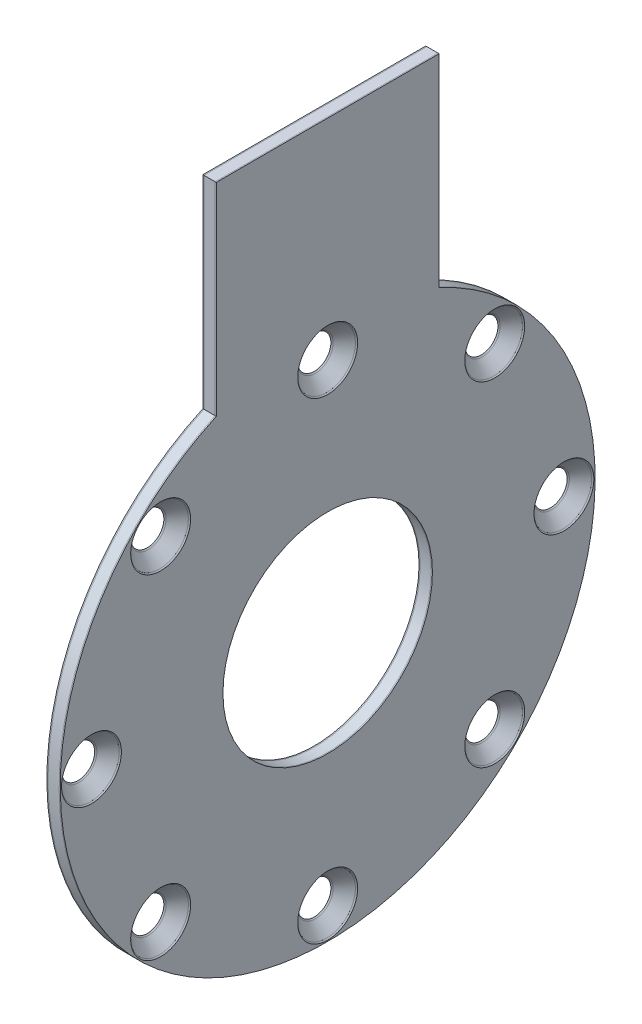
from build123d import *

# Parameters (mm, degrees)
SKETCH1_R                                    = 60
SKETCH1_R_2                                  = 23.5
BOSS_EXTRUDE1_DEPTH                          = 0.25
SKETCH4_R                                    = 23.5
BOSS_EXTRUDE4_DEPTH                          = 2.5
SKETCH5_R                                    = 23.5
BOSS_EXTRUDE5_DEPTH                          = 0.25
CSK_FOR_M6_HEX_SOCKET_COUNTERSUNK_CA_2_COUNT = 2
CSK_FOR_M6_HEX_SOCKET_COUNTERSUNK_CA_2_PITCH = 40.564443831
CSK_FOR_M6_HEX_SOCKET_COUNTERSUNK_CA_3_COUNT = 2
CSK_FOR_M6_HEX_SOCKET_COUNTERSUNK_CA_3_PITCH = 74.953318806
CSK_FOR_M6_HEX_SOCKET_COUNTERSUNK_CA_4_COUNT = 2
CSK_FOR_M6_HEX_SOCKET_COUNTERSUNK_CA_4_PITCH = 97.931230446
CSK_FOR_M6_HEX_SOCKET_COUNTERSUNK_CA_5_COUNT = 2
CSK_FOR_M6_HEX_SOCKET_COUNTERSUNK_CA_5_PITCH = 106
CSK_FOR_M6_HEX_SOCKET_COUNTERSUNK_CA_6_COUNT = 2
CSK_FOR_M6_HEX_SOCKET_COUNTERSUNK_CA_6_PITCH = 97.931230446
CSK_FOR_M6_HEX_SOCKET_COUNTERSUNK_CA_7_COUNT = 2
CSK_FOR_M6_HEX_SOCKET_COUNTERSUNK_CA_7_PITCH = 74.953318806
CSK_FOR_M6_HEX_SOCKET_COUNTERSUNK_CA_8_COUNT = 2
CSK_FOR_M6_HEX_SOCKET_COUNTERSUNK_CA_8_PITCH = 40.564443831


with BuildPart() as part:
    # Sketch1 → Boss-Extrude1 (new body)
    with BuildSketch(Plane(origin=(0, 0, 0), x_dir=(0, 0, -1), z_dir=(1, 0, 0))):
        with BuildLine():
            Line((25, 100), (-25, 100))
            Line((-25, 100), (-25, 54.543560573))
            ThreePointArc((-25, 54.543560573), (0, 60), (25, 54.543560573))
            Line((25, 54.543560573), (25, 100))
        make_face()
        Circle(SKETCH1_R)
        Circle(SKETCH1_R_2, mode=Mode.SUBTRACT)
    extrude(amount=BOSS_EXTRUDE1_DEPTH)


with BuildPart() as body_2:
    # Sketch4 → Boss-Extrude4 (new body)
    with BuildSketch(Plane.ZY):
        with BuildLine():
            Line((25, 54.543560573), (25, 100))
            Line((25, 100), (-25, 100))
            Line((-25, 100), (-25, 54.543560573))
            ThreePointArc((-25, 54.543560573), (0, -60), (25, 54.543560573))
        make_face()
        Circle(SKETCH4_R, mode=Mode.SUBTRACT)
    extrude(amount=BOSS_EXTRUDE4_DEPTH)


with BuildPart() as body_3:
    # Sketch5 → Boss-Extrude5 (new body)
    with BuildSketch(Plane.ZY.offset(2.5)):
        with BuildLine():
            Line((25, 54.543560573), (25, 100))
            Line((25, 100), (-25, 100))
            Line((-25, 100), (-25, 54.543560573))
            ThreePointArc((-25, 54.543560573), (0, -60), (25, 54.543560573))
        make_face()
        Circle(SKETCH5_R, mode=Mode.SUBTRACT)
    extrude(amount=BOSS_EXTRUDE5_DEPTH)


with BuildPart() as csk_for_m6_hex_socket_countersunk_cap_sc_tool:
    # Sketch10 → CSK for M6 Hex Socket Countersunk Cap Screw2 (revolve)
    with BuildSketch(Plane(origin=(0.25, 37.476659403, -37.476659403), x_dir=(0, 0, -1), z_dir=(0, 1, 0))):
        Polygon((0, 0), (0, 3), (3.3, 3), (3.3, 3.42), (6.72, 0), align=None)
    csk_for_m6_hex_socket_countersunk_cap_sc = revolve(axis=Axis((6.6, 37.476659403, -37.476659403), (-1, 0, 0)))


with BuildPart() as part_1:
    add(part.part)

    # CSK for M6 Hex Socket Countersunk Cap Screw2: cut by csk_for_m6_hex_socket_countersunk_cap_sc_tool
    add(csk_for_m6_hex_socket_countersunk_cap_sc_tool.part, mode=Mode.SUBTRACT)


with BuildPart() as body_2_1:
    add(body_2.part)

    # CSK for M6 Hex Socket Countersunk Cap Screw2: cut by csk_for_m6_hex_socket_countersunk_cap_sc_tool
    add(csk_for_m6_hex_socket_countersunk_cap_sc_tool.part, mode=Mode.SUBTRACT)


with BuildPart() as body_3_1:
    add(body_3.part)

    # CSK for M6 Hex Socket Countersunk Cap Screw2: cut by csk_for_m6_hex_socket_countersunk_cap_sc_tool
    add(csk_for_m6_hex_socket_countersunk_cap_sc_tool.part, mode=Mode.SUBTRACT)


with BuildPart() as csk_for_m6_hex_socket_countersunk_ca_2_tool:
    # CSK for M6 Hex Socket Countersunk Ca 2: CSK for M6 Hex Socket Countersunk Cap Screw2 ×2
    with Locations(*[Vector(0, -0.923879533, -0.382683432) * (i * CSK_FOR_M6_HEX_SOCKET_COUNTERSUNK_CA_2_PITCH) for i in range(1, CSK_FOR_M6_HEX_SOCKET_COUNTERSUNK_CA_2_COUNT)]):
        add(csk_for_m6_hex_socket_countersunk_cap_sc)


with BuildPart() as part_2:
    add(part_1.part)

    # CSK for M6 Hex Socket Countersunk Ca 2: cut by csk_for_m6_hex_socket_countersunk_ca_2_tool
    add(csk_for_m6_hex_socket_countersunk_ca_2_tool.part, mode=Mode.SUBTRACT)


with BuildPart() as body_2_2:
    add(body_2_1.part)

    # CSK for M6 Hex Socket Countersunk Ca 2: cut by csk_for_m6_hex_socket_countersunk_ca_2_tool
    add(csk_for_m6_hex_socket_countersunk_ca_2_tool.part, mode=Mode.SUBTRACT)


with BuildPart() as body_3_2:
    add(body_3_1.part)

    # CSK for M6 Hex Socket Countersunk Ca 2: cut by csk_for_m6_hex_socket_countersunk_ca_2_tool
    add(csk_for_m6_hex_socket_countersunk_ca_2_tool.part, mode=Mode.SUBTRACT)


with BuildPart() as csk_for_m6_hex_socket_countersunk_ca_3_tool:
    # CSK for M6 Hex Socket Countersunk Ca 3: CSK for M6 Hex Socket Countersunk Cap Screw2 ×2
    with Locations(*[(0, -i * CSK_FOR_M6_HEX_SOCKET_COUNTERSUNK_CA_3_PITCH, 0) for i in range(1, CSK_FOR_M6_HEX_SOCKET_COUNTERSUNK_CA_3_COUNT)]):
        add(csk_for_m6_hex_socket_countersunk_cap_sc)


with BuildPart() as part_3:
    add(part_2.part)

    # CSK for M6 Hex Socket Countersunk Ca 3: cut by csk_for_m6_hex_socket_countersunk_ca_3_tool
    add(csk_for_m6_hex_socket_countersunk_ca_3_tool.part, mode=Mode.SUBTRACT)


with BuildPart() as body_2_3:
    add(body_2_2.part)

    # CSK for M6 Hex Socket Countersunk Ca 3: cut by csk_for_m6_hex_socket_countersunk_ca_3_tool
    add(csk_for_m6_hex_socket_countersunk_ca_3_tool.part, mode=Mode.SUBTRACT)


with BuildPart() as body_3_3:
    add(body_3_2.part)

    # CSK for M6 Hex Socket Countersunk Ca 3: cut by csk_for_m6_hex_socket_countersunk_ca_3_tool
    add(csk_for_m6_hex_socket_countersunk_ca_3_tool.part, mode=Mode.SUBTRACT)


with BuildPart() as csk_for_m6_hex_socket_countersunk_ca_4_tool:
    # CSK for M6 Hex Socket Countersunk Ca 4: CSK for M6 Hex Socket Countersunk Cap Screw2 ×2
    with Locations(*[Vector(0, -0.923879533, 0.382683432) * (i * CSK_FOR_M6_HEX_SOCKET_COUNTERSUNK_CA_4_PITCH) for i in range(1, CSK_FOR_M6_HEX_SOCKET_COUNTERSUNK_CA_4_COUNT)]):
        add(csk_for_m6_hex_socket_countersunk_cap_sc)


with BuildPart() as part_4:
    add(part_3.part)

    # CSK for M6 Hex Socket Countersunk Ca 4: cut by csk_for_m6_hex_socket_countersunk_ca_4_tool
    add(csk_for_m6_hex_socket_countersunk_ca_4_tool.part, mode=Mode.SUBTRACT)


with BuildPart() as body_2_4:
    add(body_2_3.part)

    # CSK for M6 Hex Socket Countersunk Ca 4: cut by csk_for_m6_hex_socket_countersunk_ca_4_tool
    add(csk_for_m6_hex_socket_countersunk_ca_4_tool.part, mode=Mode.SUBTRACT)


with BuildPart() as body_3_4:
    add(body_3_3.part)

    # CSK for M6 Hex Socket Countersunk Ca 4: cut by csk_for_m6_hex_socket_countersunk_ca_4_tool
    add(csk_for_m6_hex_socket_countersunk_ca_4_tool.part, mode=Mode.SUBTRACT)


with BuildPart() as csk_for_m6_hex_socket_countersunk_ca_5_tool:
    # CSK for M6 Hex Socket Countersunk Ca 5: CSK for M6 Hex Socket Countersunk Cap Screw2 ×2
    with Locations(*[Vector(0, -0.707106781, 0.707106781) * (i * CSK_FOR_M6_HEX_SOCKET_COUNTERSUNK_CA_5_PITCH) for i in range(1, CSK_FOR_M6_HEX_SOCKET_COUNTERSUNK_CA_5_COUNT)]):
        add(csk_for_m6_hex_socket_countersunk_cap_sc)


with BuildPart() as part_5:
    add(part_4.part)

    # CSK for M6 Hex Socket Countersunk Ca 5: cut by csk_for_m6_hex_socket_countersunk_ca_5_tool
    add(csk_for_m6_hex_socket_countersunk_ca_5_tool.part, mode=Mode.SUBTRACT)


with BuildPart() as body_2_5:
    add(body_2_4.part)

    # CSK for M6 Hex Socket Countersunk Ca 5: cut by csk_for_m6_hex_socket_countersunk_ca_5_tool
    add(csk_for_m6_hex_socket_countersunk_ca_5_tool.part, mode=Mode.SUBTRACT)


with BuildPart() as body_3_5:
    add(body_3_4.part)

    # CSK for M6 Hex Socket Countersunk Ca 5: cut by csk_for_m6_hex_socket_countersunk_ca_5_tool
    add(csk_for_m6_hex_socket_countersunk_ca_5_tool.part, mode=Mode.SUBTRACT)


with BuildPart() as csk_for_m6_hex_socket_countersunk_ca_6_tool:
    # CSK for M6 Hex Socket Countersunk Ca 6: CSK for M6 Hex Socket Countersunk Cap Screw2 ×2
    with Locations(*[Vector(0, -0.382683432, 0.923879533) * (i * CSK_FOR_M6_HEX_SOCKET_COUNTERSUNK_CA_6_PITCH) for i in range(1, CSK_FOR_M6_HEX_SOCKET_COUNTERSUNK_CA_6_COUNT)]):
        add(csk_for_m6_hex_socket_countersunk_cap_sc)


with BuildPart() as part_6:
    add(part_5.part)

    # CSK for M6 Hex Socket Countersunk Ca 6: cut by csk_for_m6_hex_socket_countersunk_ca_6_tool
    add(csk_for_m6_hex_socket_countersunk_ca_6_tool.part, mode=Mode.SUBTRACT)


with BuildPart() as body_2_6:
    add(body_2_5.part)

    # CSK for M6 Hex Socket Countersunk Ca 6: cut by csk_for_m6_hex_socket_countersunk_ca_6_tool
    add(csk_for_m6_hex_socket_countersunk_ca_6_tool.part, mode=Mode.SUBTRACT)


with BuildPart() as body_3_6:
    add(body_3_5.part)

    # CSK for M6 Hex Socket Countersunk Ca 6: cut by csk_for_m6_hex_socket_countersunk_ca_6_tool
    add(csk_for_m6_hex_socket_countersunk_ca_6_tool.part, mode=Mode.SUBTRACT)


with BuildPart() as csk_for_m6_hex_socket_countersunk_ca_7_tool:
    # CSK for M6 Hex Socket Countersunk Ca 7: CSK for M6 Hex Socket Countersunk Cap Screw2 ×2
    with Locations(*[(0, 0, i * CSK_FOR_M6_HEX_SOCKET_COUNTERSUNK_CA_7_PITCH) for i in range(1, CSK_FOR_M6_HEX_SOCKET_COUNTERSUNK_CA_7_COUNT)]):
        add(csk_for_m6_hex_socket_countersunk_cap_sc)


with BuildPart() as part_7:
    add(part_6.part)

    # CSK for M6 Hex Socket Countersunk Ca 7: cut by csk_for_m6_hex_socket_countersunk_ca_7_tool
    add(csk_for_m6_hex_socket_countersunk_ca_7_tool.part, mode=Mode.SUBTRACT)


with BuildPart() as body_2_7:
    add(body_2_6.part)

    # CSK for M6 Hex Socket Countersunk Ca 7: cut by csk_for_m6_hex_socket_countersunk_ca_7_tool
    add(csk_for_m6_hex_socket_countersunk_ca_7_tool.part, mode=Mode.SUBTRACT)


with BuildPart() as body_3_7:
    add(body_3_6.part)

    # CSK for M6 Hex Socket Countersunk Ca 7: cut by csk_for_m6_hex_socket_countersunk_ca_7_tool
    add(csk_for_m6_hex_socket_countersunk_ca_7_tool.part, mode=Mode.SUBTRACT)


with BuildPart() as csk_for_m6_hex_socket_countersunk_ca_8_tool:
    # CSK for M6 Hex Socket Countersunk Ca 8: CSK for M6 Hex Socket Countersunk Cap Screw2 ×2
    with Locations(*[Vector(0, 0.382683432, 0.923879533) * (i * CSK_FOR_M6_HEX_SOCKET_COUNTERSUNK_CA_8_PITCH) for i in range(1, CSK_FOR_M6_HEX_SOCKET_COUNTERSUNK_CA_8_COUNT)]):
        add(csk_for_m6_hex_socket_countersunk_cap_sc)


with BuildPart() as part_8:
    add(part_7.part)

    # CSK for M6 Hex Socket Countersunk Ca 8: cut by csk_for_m6_hex_socket_countersunk_ca_8_tool
    add(csk_for_m6_hex_socket_countersunk_ca_8_tool.part, mode=Mode.SUBTRACT)


with BuildPart() as body_2_8:
    add(body_2_7.part)

    # CSK for M6 Hex Socket Countersunk Ca 8: cut by csk_for_m6_hex_socket_countersunk_ca_8_tool
    add(csk_for_m6_hex_socket_countersunk_ca_8_tool.part, mode=Mode.SUBTRACT)


with BuildPart() as body_3_8:
    add(body_3_7.part)

    # CSK for M6 Hex Socket Countersunk Ca 8: cut by csk_for_m6_hex_socket_countersunk_ca_8_tool
    add(csk_for_m6_hex_socket_countersunk_ca_8_tool.part, mode=Mode.SUBTRACT)


solid = Compound([part_8.part, body_2_8.part, body_3_8.part])
